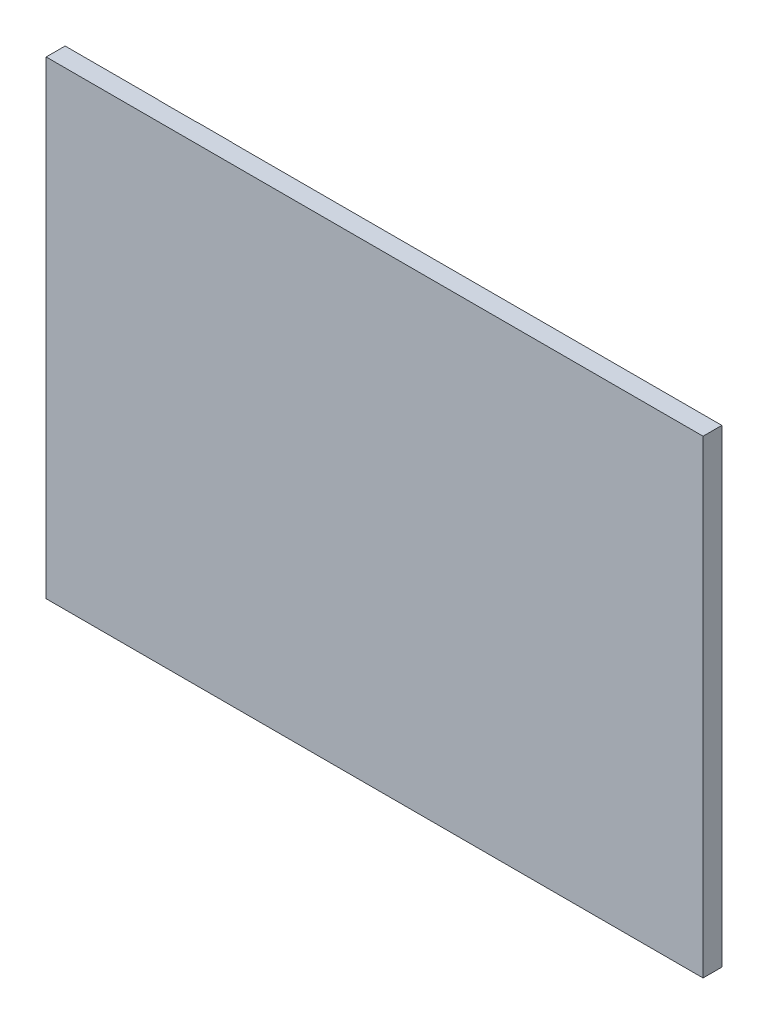
from build123d import *

# Parameters (mm, degrees)
ESBO_O1_W                = 350
ESBO_O1_H                = 250
RESSALTO_EXTRUS_O1_DEPTH = 10
ESBO_O2_W                = 50
ESBO_O2_H                = 250
ESBO_O2_W_2              = 19
RESSALTO_EXTRUS_O2_DEPTH = 0.1


with BuildPart() as part:
    # Esboço1 → Ressalto-extrusão1 (new body)
    with BuildSketch(Plane.XY):
        Rectangle(ESBO_O1_W, ESBO_O1_H)
    extrude(amount=RESSALTO_EXTRUS_O1_DEPTH)

    # Esboço2 → Ressalto-extrusão2 (add)
    with BuildSketch(Plane(origin=(0, 0, 0), x_dir=(-1, 0, 0), z_dir=(0, 0, -1))):
        with Locations((150, 0)):
            Rectangle(ESBO_O2_W, ESBO_O2_H)
        with Locations((95.5, 0)):
            Rectangle(ESBO_O2_W_2, ESBO_O2_H)
    extrude(amount=RESSALTO_EXTRUS_O2_DEPTH)


solid = part.part
